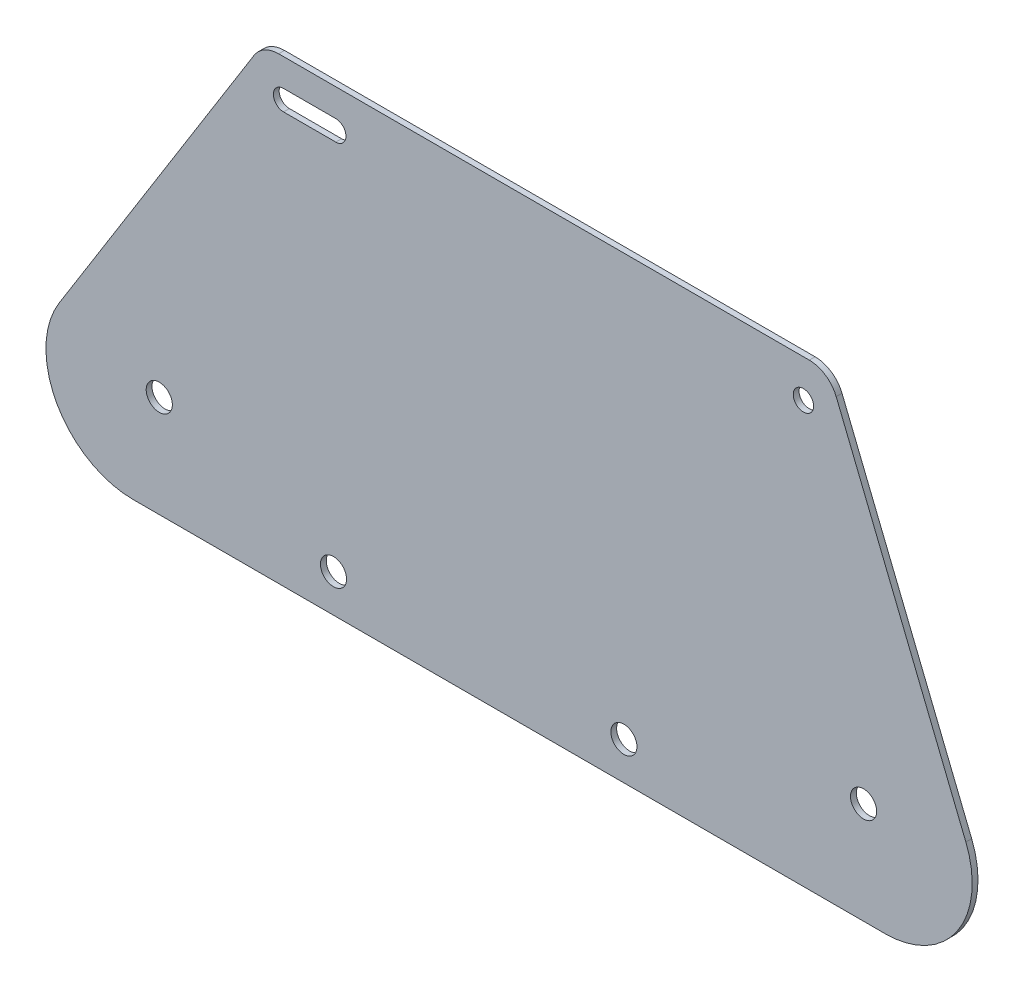
from build123d import *

# Parameters (mm, degrees)
SKETCH1_R           = 3.5
SKETCH1_R_2         = 4.5
BOSS_EXTRUDE1_DEPTH = 2
FILLET1_R           = 30
FILLET2_R           = 10


with BuildPart() as part:
    # Sketch1 → Boss-Extrude1 (new body)
    with BuildSketch(Plane.XY):
        Polygon((0, 0), (98.729357602, 158), (293.729357602, 158), (357.565501284, 0), align=None)
        with Locations((284.960746883, 145)):
            Circle(SKETCH1_R, mode=Mode.SUBTRACT)
        with Locations((305.675867386, 35)):
            Circle(SKETCH1_R_2, mode=Mode.SUBTRACT)
        with Locations((63.141671434, 35)):
            Circle(SKETCH1_R_2, mode=Mode.SUBTRACT)
        with Locations((123.141671434, 13)):
            Circle(SKETCH1_R_2, mode=Mode.SUBTRACT)
        with Locations((223.141671434, 13)):
            Circle(SKETCH1_R_2, mode=Mode.SUBTRACT)
        with BuildLine():
            Line((105.935375271, 148.5), (123.935375271, 148.5))
            ThreePointArc((123.935375271, 148.5), (127.435375271, 145), (123.935375271, 141.5))
            Line((123.935375271, 141.5), (105.935375271, 141.5))
            ThreePointArc((105.935375271, 141.5), (102.435375271, 145), (105.935375271, 148.5))
        make_face(mode=Mode.SUBTRACT)
    extrude(amount=BOSS_EXTRUDE1_DEPTH)

    # Fillet1
    fillet1_edges = [part.edges().sort_by_distance(p)[0] for p in [
        (0, 0, 1),
        (357.565501284, 0, 1),
    ]]
    fillet(fillet1_edges, radius=FILLET1_R)

    # Fillet2
    fillet2_edges = [part.edges().sort_by_distance(p)[0] for p in [
        (98.729357602, 158, 1),
        (293.729357602, 158, 1),
    ]]
    fillet(fillet2_edges, radius=FILLET2_R)


solid = part.part
